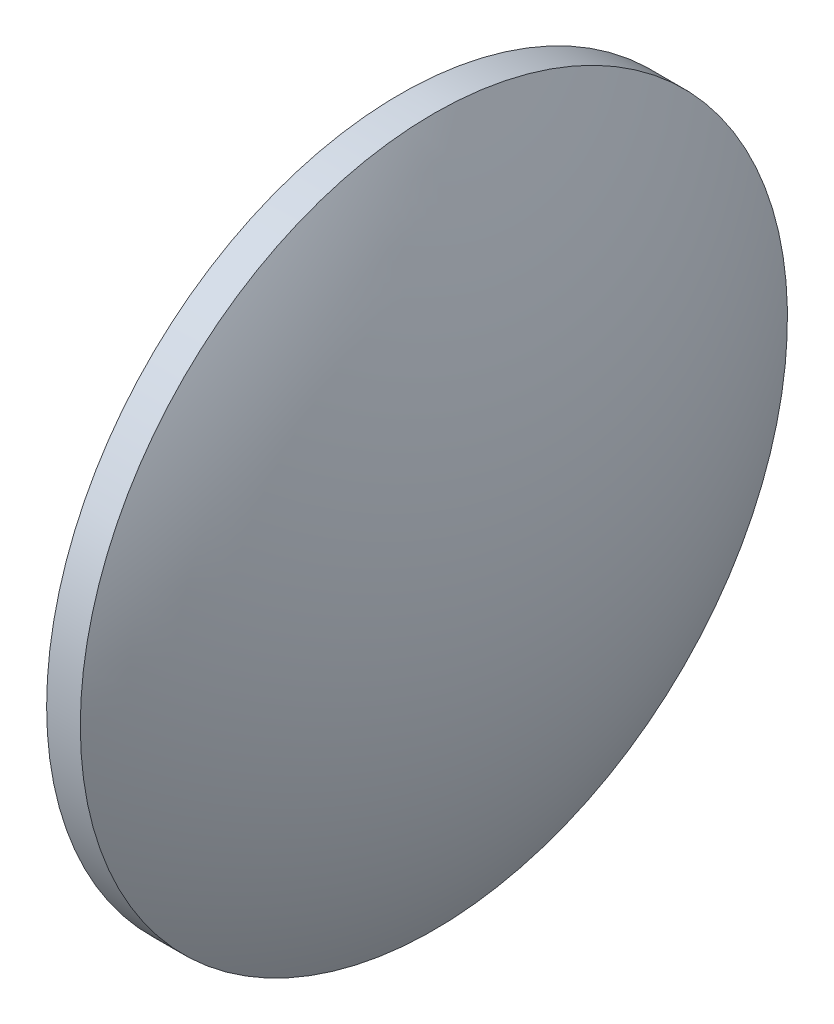
from build123d import *


with BuildPart() as part:
    # 草图1 → 旋转1 (revolve)
    with BuildSketch(Plane.XY):
        with BuildLine():
            Line((226.893301001, 130.518581457), (226.893301001, 162.018581457))
            Line((226.893301001, 162.018581457), (229.893301001, 162.018581457))
            ThreePointArc((229.893301001, 162.018581457), (236.017080064, 146.794745778), (238.103301001, 130.518581457))
            Line((238.103301001, 130.518581457), (226.893301001, 130.518581457))
        make_face()
    revolve(axis=Axis((218.123666737, 130.518581457, 0), (1, 0, 0)))


solid = part.part
